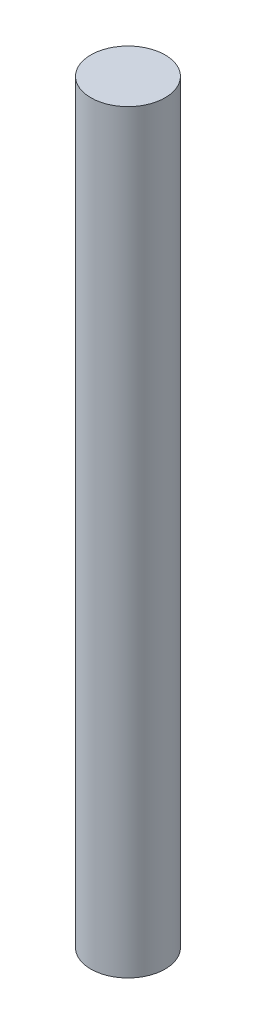
from build123d import *

# Parameters (mm, degrees)
SKETCH1_R           = 1.25
BOSS_EXTRUDE1_DEPTH = 25.4


with BuildPart() as part:
    # Sketch1 → Boss-Extrude1 (new body)
    with BuildSketch(Plane(origin=(0, 0, 0), x_dir=(1, 0, 0), z_dir=(0, 1, 0))):
        Circle(SKETCH1_R)
    extrude(amount=BOSS_EXTRUDE1_DEPTH)


solid = part.part
